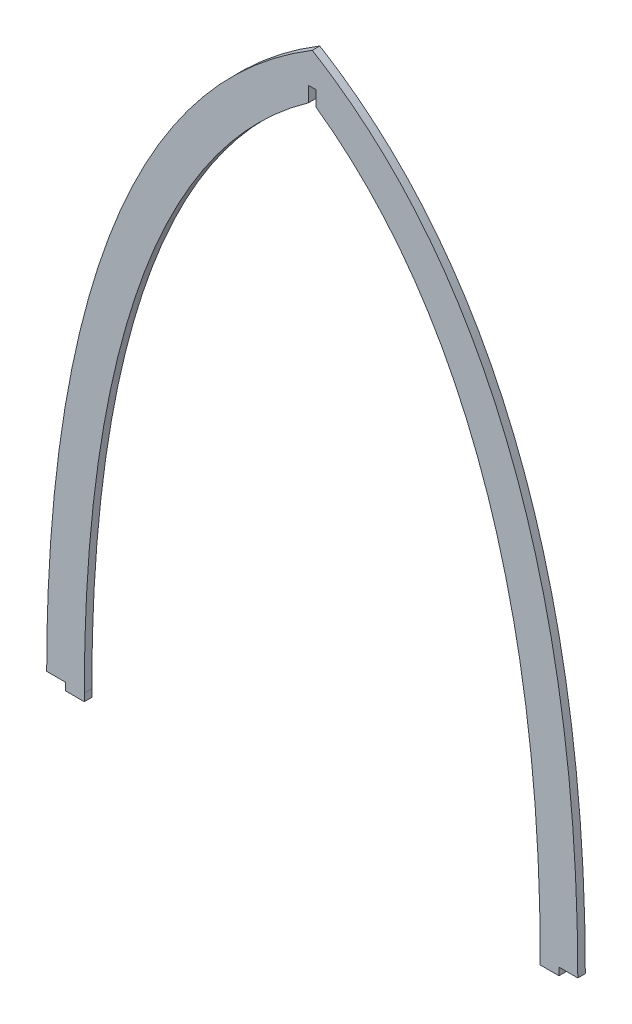
from build123d import *

# Parameters (mm, degrees)
BOSS_EXTRUDE1_DEPTH = 1.5


with BuildPart() as part:
    # Sketch1 → Boss-Extrude1 (new, symmetric)
    with BuildSketch(Plane.XY):
        with BuildLine():
            Line((-106, 162), (-98.5, 162))
            Line((-98.5, 162), (-98.5, 159))
            Line((-98.5, 159), (-91, 159))
            Line((-91, 159), (-91, 162))
            add(Edge.make_bspline(
                [(-91, 162), (-91, 163.331524141), (-90.992376318, 165.983870931), (-90.945171024, 171.374041262), (-90.823504223, 178.205929247), (-90.568516042, 186.555758505), (-90.071645038, 197.860045048), (-89.134789291, 212.26907526), (-87.43709218, 229.859021299), (-85.098976262, 247.601905442), (-81.040866449, 271.26711415), (-74.045466816, 300.495547841), (-62.102149991, 333.833287872), (-48.848124705, 359.221840008), (-36.073317005, 377.590452103), (-25.355695414, 390.287212667), (-15.418026325, 399.891290702), (-7.305039618, 406.550984174), (-3.288780832, 409.527699977), (-1.5, 410.793822053)],
                knots=[0, 0, 0, 0, 0.015112969, 0.030225939, 0.060451877, 0.090677816, 0.120903754, 0.181355631, 0.241807508, 0.302259385, 0.362711262, 0.483615016, 0.60451877, 0.725422524, 0.785874401, 0.846326278, 0.906778155, 0.937004094, 0.960647293, 0.960647293, 0.960647293, 0.960647293], degree=3))
            Line((-1.5, 410.793822053), (-1.5, 416.841652361))
            Line((-1.5, 416.841652361), (1.5, 416.841652361))
            Line((1.5, 416.841652361), (1.5, 410.793822053))
            add(Edge.make_bspline(
                [(1.5, 410.793822053), (3.288780833, 409.527699976), (7.305039619, 406.550984173), (15.418026325, 399.891290702), (25.355695414, 390.287212667), (36.073317005, 377.590452103), (48.848124705, 359.221840008), (62.102149991, 333.833287872), (74.045466816, 300.495547841), (81.040866449, 271.26711415), (85.098976262, 247.601905442), (87.43709218, 229.859021299), (89.134789291, 212.26907526), (90.071645038, 197.860045048), (90.568516042, 186.555758505), (90.823504223, 178.205929247), (90.945171024, 171.374041262), (90.992376318, 165.983870931), (91, 163.331524141), (91, 162)],
                knots=[0.00658274, 0.00658274, 0.00658274, 0.00658274, 0.030225939, 0.060451877, 0.120903754, 0.181355631, 0.241807508, 0.362711262, 0.483615016, 0.60451877, 0.664970647, 0.725422524, 0.785874401, 0.846326278, 0.876552217, 0.906778155, 0.937004094, 0.952117063, 0.967230032, 0.967230032, 0.967230032, 0.967230032], degree=3))
            Line((91, 162), (91, 159))
            Line((91, 159), (98.5, 159))
            Line((98.5, 159), (98.5, 162))
            Line((98.5, 162), (106, 162))
            add(Edge.make_bspline(
                [(106, 162), (106, 251.51123923), (88.948086668, 376.101025723), (0, 429.683378347)],
                knots=[0, 0, 0, 0, 1, 1, 1, 1], degree=3))
            add(Edge.make_bspline(
                [(-106, 162), (-106, 251.51123923), (-88.948086668, 376.101025723), (0, 429.683378347)],
                knots=[0, 0, 0, 0, 1, 1, 1, 1], degree=3))
        make_face()
    extrude(amount=BOSS_EXTRUDE1_DEPTH, both=True)


solid = part.part
